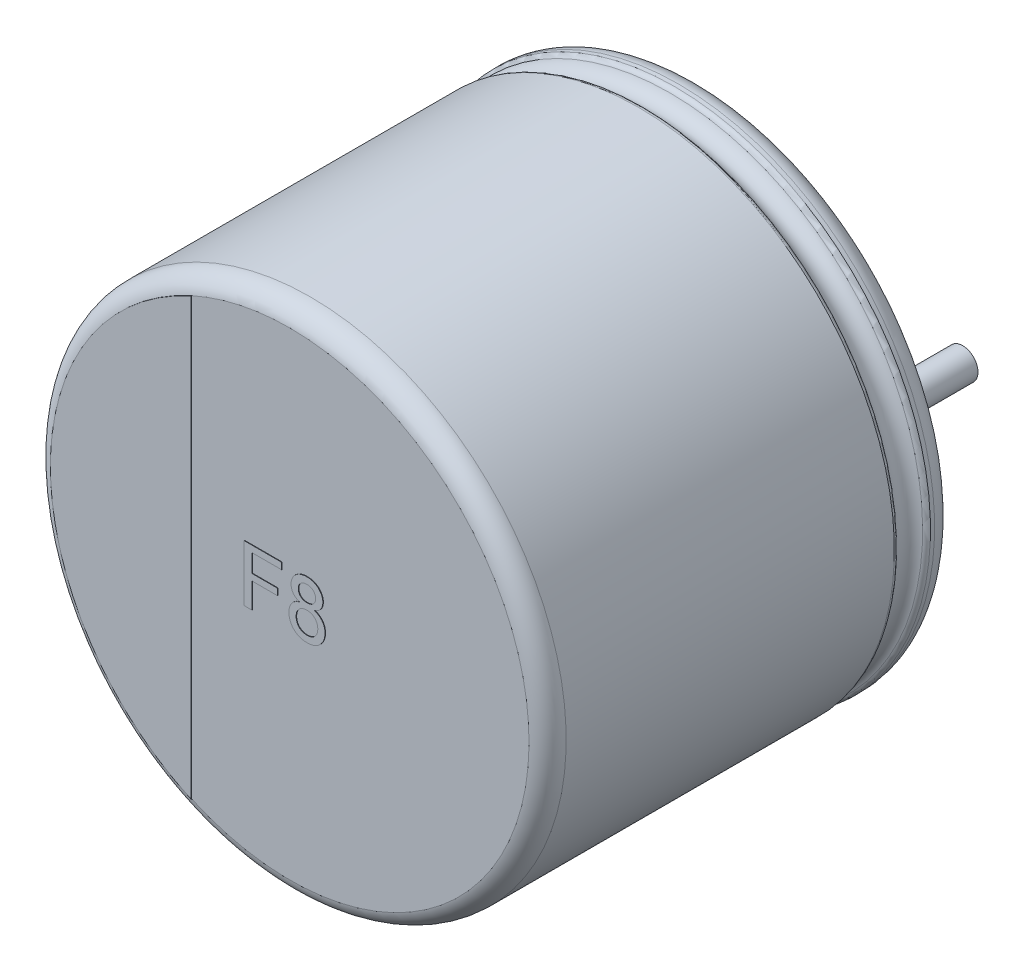
from build123d import *

# Parameters (mm, degrees)
SKETCH_2_R         = 0.3
EXTRUDE_1_DEPTH    = 2.7
EXTRUDE_2_DEPTH    = 0.01
EXTRUDE_1828_DEPTH = 0.01
EXTRUDE_5_DEPTH    = 0.05


with BuildPart() as part:
    # Sketch10 → Повернуть1 (revolve)
    with BuildSketch(Plane(origin=(0, 0, 0), x_dir=(0, 0, -1), z_dir=(1, 0, 0))):
        with BuildLine():
            Line((-8, 0), (-0.05, 0))
            Line((-0.05, 0), (-0.05, 4.403143426))
            ThreePointArc((-0.05, 4.403143426), (-0.052704561, 4.801565585), (-0.398206102, 5))
            Line((-0.398206102, 5), (-0.479422929, 5))
            ThreePointArc((-0.479422929, 5), (-0.534479696, 4.983479053), (-0.571344666, 4.939375046))
            ThreePointArc((-0.571344666, 4.939375046), (-0.831990181, 4.767472047), (-1.092635697, 4.939375046))
            ThreePointArc((-1.092635697, 4.939375046), (-1.129500666, 4.983479053), (-1.184557434, 5))
            Line((-1.184557434, 5), (-7.6, 5))
            ThreePointArc((-7.6, 5), (-7.85971595, 4.909961924), (-8, 4.67357323))
            Line((-8, 4.67357323), (-8, 0))
        make_face()
    revolve(axis=Axis((0, 0, -18.1630778), (0, 0, 1)))

    # Эскиз2 → Бобышка-Вытянуть1 (add)
    with BuildSketch(Plane(origin=(0, 0, 0.05), x_dir=(-1, 0, 0), z_dir=(0, 0, -1))):
        with Locations((-2.5, 0)):
            Circle(SKETCH_2_R)
        with Locations((2.5, 0)):
            Circle(SKETCH_2_R)
    extrude(amount=EXTRUDE_1_DEPTH)

    # Эскиз4 → Бобышка-Вытянуть2 (add)
    with BuildSketch(Plane.XY.offset(8)):
        with BuildLine():
            Line((-1.920580247, -4.260711003), (-1.920580247, 4.260711003))
            ThreePointArc((-1.920580247, 4.260711003), (-4.67357323, 0), (-1.920580247, -4.260711003))
        make_face()
    extrude(amount=EXTRUDE_2_DEPTH)

    # Эскиз5 → Extrude 1828 (add)
    with BuildSketch(Plane.XY.offset(8)):
        Polygon((-0.884369756, -0.464160183), (-0.884369756, 0.635839817), (-0.151036423, 0.635839817), (-0.151036423, 0.50891674), (-0.729241551, 0.50891674), (-0.729241551, 0.156352638), (-0.235651808, 0.156352638), (-0.235651808, 0.029429561), (-0.729241551, 0.029429561), (-0.729241551, -0.464160183), align=None)
        with BuildLine():
            add(Edge.make_bspline(
                [(0.198883449, 0.139165138), (0.185502606, 0.144399799), (0.159847092, 0.154436381), (0.125244419, 0.174522407), (0.095958787, 0.197628735), (0.072349786, 0.224312558), (0.054355434, 0.25402225), (0.04139879, 0.286379012), (0.033809856, 0.321563108), (0.032811064, 0.345892004), (0.03229691, 0.358415939)],
                knots=[0, 0, 0, 0, 4.3054e-05, 8.2549e-05, 0.000119543, 0.000154513, 0.000188827, 0.00022324, 0.000258637, 0.00029619, 0.00029619, 0.00029619, 0.00029619], degree=3))
            add(Edge.make_bspline(
                [(0.03229691, 0.358415939), (0.032538899, 0.368052555), (0.033013929, 0.386969534), (0.037118303, 0.414726997), (0.043692048, 0.441325591), (0.05302173, 0.466690245), (0.064710293, 0.491029732), (0.079459288, 0.513898142), (0.096412342, 0.535941783), (0.116272039, 0.556269584), (0.138157081, 0.574887882), (0.161861998, 0.591456339), (0.187568179, 0.605005308), (0.214847028, 0.616333389), (0.243833428, 0.625202078), (0.274629482, 0.631242149), (0.307126629, 0.635084083), (0.329394445, 0.635583982), (0.3407905, 0.635839817)],
                knots=[0, 0, 0, 0, 2.8896e-05, 5.6725e-05, 8.3981e-05, 0.000110958, 0.000137666, 0.000164808, 0.000192444, 0.000220962, 0.000249881, 0.000278549, 0.000307531, 0.000336872, 0.000367054, 0.000398298, 0.000430906, 0.000465086, 0.000465086, 0.000465086, 0.000465086], degree=3))
            add(Edge.make_bspline(
                [(0.3407905, 0.635839817), (0.352259172, 0.635581385), (0.37459885, 0.635077988), (0.407268648, 0.631287675), (0.438259045, 0.624934875), (0.467551797, 0.61592185), (0.495193084, 0.604398156), (0.521001276, 0.590234023), (0.545242053, 0.573663062), (0.567295828, 0.55448766), (0.587362135, 0.533669409), (0.604747694, 0.511366016), (0.619658735, 0.488097915), (0.63198047, 0.463723748), (0.641096136, 0.437965957), (0.64804432, 0.411309831), (0.652074588, 0.383438644), (0.652561626, 0.364525143), (0.652809731, 0.354890298)],
                knots=[0, 0, 0, 0, 3.44e-05, 6.7008e-05, 9.8512e-05, 0.00012918, 0.000158809, 0.000188196, 0.00021735, 0.000246724, 0.000275712, 0.000303967, 0.000331413, 0.000358513, 0.000385698, 0.000413222, 0.00044105, 0.000469946, 0.000469946, 0.000469946, 0.000469946], degree=3))
            add(Edge.make_bspline(
                [(0.652809731, 0.354890298), (0.652406692, 0.342798008), (0.651616409, 0.319087304), (0.64356307, 0.284908125), (0.631011253, 0.25300015), (0.612870089, 0.223971487), (0.589894979, 0.197522335), (0.561384701, 0.174529798), (0.527772233, 0.154475164), (0.502764481, 0.144405855), (0.489748833, 0.139165138)],
                knots=[0, 0, 0, 0, 3.6219e-05, 7.1019e-05, 0.000104736, 0.000138674, 0.000173188, 0.000209359, 0.000248094, 0.000290135, 0.000290135, 0.000290135, 0.000290135], degree=3))
            add(Edge.make_bspline(
                [(0.489748833, 0.139165138), (0.497960862, 0.136377543), (0.514052876, 0.130915067), (0.536802182, 0.12029433), (0.55821997, 0.108842655), (0.578427016, 0.096446209), (0.596677431, 0.082183099), (0.613580099, 0.066896643), (0.629063956, 0.050371426), (0.642917509, 0.032466898), (0.655285909, 0.013558844), (0.665874242, -0.006398833), (0.674866709, -0.027122063), (0.682551982, -0.048706942), (0.688165466, -0.071305513), (0.692093145, -0.094813923), (0.694585147, -0.119108275), (0.694938153, -0.135608468), (0.695117423, -0.143987907)],
                knots=[0, 0, 0, 0, 2.5999e-05, 5.0946e-05, 7.5198e-05, 9.8859e-05, 0.000121954, 0.000144573, 0.00016718, 0.000189791, 0.000212405, 0.000234881, 0.000257479, 0.000280128, 0.000303536, 0.000327228, 0.000351588, 0.000376723, 0.000376723, 0.000376723, 0.000376723], degree=3))
            add(Edge.make_bspline(
                [(0.695117423, -0.143987907), (0.694837165, -0.155537045), (0.694285035, -0.178289726), (0.689433844, -0.211687991), (0.682093778, -0.243771583), (0.671391114, -0.274404967), (0.657721153, -0.303609799), (0.640811246, -0.331343671), (0.620827539, -0.357578052), (0.598359515, -0.382394488), (0.573240279, -0.404827472), (0.546065918, -0.42459588), (0.516734471, -0.441154442), (0.485601829, -0.454864872), (0.452518917, -0.465490405), (0.417528262, -0.47293053), (0.380641507, -0.477360798), (0.355419487, -0.477958069), (0.342553321, -0.478262747)],
                knots=[0, 0, 0, 0, 3.463e-05, 6.8223e-05, 0.000101041, 0.000133237, 0.000165372, 0.000197607, 0.000230484, 0.000264176, 0.000297883, 0.000331338, 0.000364791, 0.000398732, 0.000433226, 0.000468839, 0.000505901, 0.000544493, 0.000544493, 0.000544493, 0.000544493], degree=3))
            add(Edge.make_bspline(
                [(0.342553321, -0.478262747), (0.329688441, -0.477951503), (0.304468944, -0.47734136), (0.267548487, -0.473001662), (0.232607895, -0.465224256), (0.199568, -0.454587923), (0.16824957, -0.441248704), (0.139115111, -0.424317035), (0.111763248, -0.404573672), (0.086626545, -0.382001935), (0.063971892, -0.357188146), (0.044251614, -0.330566323), (0.027442092, -0.302546168), (0.01360822, -0.272969725), (0.003063656, -0.241836724), (-0.004336645, -0.209264049), (-0.009196616, -0.175276591), (-0.009735569, -0.152084695), (-0.010010782, -0.140241914)],
                knots=[0, 0, 0, 0, 3.8593e-05, 7.5654e-05, 0.000111314, 0.000145808, 0.000179661, 0.000213224, 0.000246678, 0.000280697, 0.000314389, 0.00034731, 0.000379923, 0.000412257, 0.000445078, 0.000478325, 0.000512355, 0.000547865, 0.000547865, 0.000547865, 0.000547865], degree=3))
            add(Edge.make_bspline(
                [(-0.010010782, -0.140241914), (-0.009819488, -0.131424081), (-0.009444137, -0.114121969), (-0.007151245, -0.088744477), (-0.002581555, -0.064557061), (0.003304497, -0.041417182), (0.010777941, -0.019266953), (0.019997857, 0.001719682), (0.031183991, 0.021492), (0.043892172, 0.040178659), (0.058282763, 0.057648472), (0.074122527, 0.07374845), (0.091469, 0.088295469), (0.109932376, 0.101714403), (0.130286574, 0.113056035), (0.151774628, 0.123464095), (0.174765975, 0.132340241), (0.190763778, 0.136867388), (0.198883449, 0.139165138)],
                knots=[0, 0, 0, 0, 2.6457e-05, 5.1913e-05, 7.6333e-05, 0.000100222, 0.000123496, 0.000146384, 0.000168879, 0.000191554, 0.000214096, 0.00023669, 0.000259205, 0.000281951, 0.000305046, 0.000328996, 0.000353549, 0.000378855, 0.000378855, 0.000378855, 0.000378855], degree=3))
        make_face()
        with BuildLine():
            add(Edge.make_bspline(
                [(0.173322551, 0.357754881), (0.173741114, 0.346528252), (0.174549962, 0.324833422), (0.183346276, 0.294017507), (0.197101157, 0.266336173), (0.213226342, 0.246262311), (0.228686344, 0.23258495), (0.241589845, 0.223453062), (0.255690876, 0.215700274), (0.271091593, 0.209674318), (0.28741899, 0.204335696), (0.305236175, 0.201351795), (0.324124366, 0.19892606), (0.337182213, 0.19875038), (0.343875436, 0.19866033)],
                knots=[0, 0, 0, 0, 3.3598e-05, 6.4926e-05, 9.5278e-05, 0.000125837, 0.000141446, 0.000157097, 0.000173171, 0.00018958, 0.000206655, 0.000224591, 0.000243669, 0.000263732, 0.000263732, 0.000263732, 0.000263732], degree=3))
            add(Edge.make_bspline(
                [(0.343875436, 0.19866033), (0.350420912, 0.198753708), (0.363184232, 0.19893579), (0.381647016, 0.201312071), (0.399094283, 0.204485818), (0.415268213, 0.209295143), (0.430355533, 0.215548669), (0.444110855, 0.223257723), (0.456945804, 0.232117638), (0.471951648, 0.245899493), (0.48805458, 0.265270289), (0.501855558, 0.291715059), (0.510455739, 0.320647206), (0.511333533, 0.340800134), (0.51178409, 0.351144304)],
                knots=[0, 0, 0, 0, 1.9623e-05, 3.8263e-05, 5.5765e-05, 7.2777e-05, 8.8778e-05, 0.000104658, 0.000120003, 0.000135448, 0.000165665, 0.000195037, 0.000224397, 0.00025536, 0.00025536, 0.00025536, 0.00025536], degree=3))
            add(Edge.make_bspline(
                [(0.51178409, 0.351144304), (0.511241232, 0.361850078), (0.510178999, 0.382798504), (0.501599825, 0.412870914), (0.487156034, 0.440107537), (0.470656006, 0.459998057), (0.455384708, 0.474407567), (0.442319335, 0.483580186), (0.428274009, 0.491386895), (0.413195276, 0.497762125), (0.397061329, 0.502903814), (0.379828465, 0.506277009), (0.361569095, 0.50864275), (0.349025285, 0.508823488), (0.342553321, 0.50891674)],
                knots=[0, 0, 0, 0, 3.2079e-05, 6.2771e-05, 9.2933e-05, 0.000123941, 0.000139846, 0.000155805, 0.000171686, 0.000187975, 0.000204841, 0.000222386, 0.000240589, 0.000259991, 0.000259991, 0.000259991, 0.000259991], degree=3))
            add(Edge.make_bspline(
                [(0.342553321, 0.50891674), (0.336080636, 0.508826504), (0.323462453, 0.508650594), (0.30508402, 0.506213862), (0.28768784, 0.503153376), (0.271434404, 0.498241863), (0.256391273, 0.491823657), (0.242401322, 0.484012562), (0.229360704, 0.475074244), (0.213982115, 0.461307276), (0.197875577, 0.441936041), (0.18368617, 0.415913626), (0.174916657, 0.387540412), (0.173860501, 0.367806367), (0.173322551, 0.357754881)],
                knots=[0, 0, 0, 0, 1.9402e-05, 3.7824e-05, 5.5543e-05, 7.2343e-05, 8.8633e-05, 0.000104513, 0.000120345, 0.000135954, 0.000166312, 0.000195399, 0.000224399, 0.000254503, 0.000254503, 0.000254503, 0.000254503], degree=3))
        make_face(mode=Mode.SUBTRACT)
        with BuildLine():
            add(Edge.make_bspline(
                [(0.131014859, -0.137597683), (0.131258724, -0.14664666), (0.131747097, -0.164768452), (0.136031177, -0.191683153), (0.143300372, -0.218096652), (0.152617112, -0.2440339), (0.165758953, -0.268448024), (0.183186511, -0.290239426), (0.205054833, -0.308560323), (0.230029653, -0.324038512), (0.257283602, -0.336221178), (0.285683015, -0.344725093), (0.314494915, -0.350344055), (0.333933916, -0.35100776), (0.343655083, -0.35133967)],
                knots=[0, 0, 0, 0, 2.7136e-05, 5.4343e-05, 8.1496e-05, 0.000109247, 0.000136857, 0.000164284, 0.000192415, 0.000222009, 0.000252191, 0.000281676, 0.000310806, 0.000339946, 0.000339946, 0.000339946, 0.000339946], degree=3))
            add(Edge.make_bspline(
                [(0.343655083, -0.35133967), (0.351671235, -0.351203882), (0.367244331, -0.350940085), (0.389945031, -0.34792564), (0.411334221, -0.343351741), (0.431509897, -0.337080176), (0.450175095, -0.328500259), (0.46763377, -0.3184722), (0.483707342, -0.306352522), (0.498391261, -0.292520912), (0.511535971, -0.277220558), (0.522796078, -0.260714819), (0.532618402, -0.243467879), (0.54063788, -0.225107523), (0.546437255, -0.205595888), (0.550912293, -0.185285008), (0.55361195, -0.163965388), (0.55392952, -0.149431045), (0.554091782, -0.142004734)],
                knots=[0, 0, 0, 0, 2.4035e-05, 4.6692e-05, 6.8562e-05, 8.9607e-05, 0.000109923, 0.000130067, 0.000149899, 0.000170164, 0.000190479, 0.000210283, 0.000230016, 0.000249952, 0.000270235, 0.000290981, 0.0003123, 0.000334573, 0.000334573, 0.000334573, 0.000334573], degree=3))
            add(Edge.make_bspline(
                [(0.554091782, -0.142004734), (0.553924352, -0.134432654), (0.553596552, -0.119607726), (0.550965501, -0.097820183), (0.546239533, -0.077151964), (0.540161917, -0.057290831), (0.531925011, -0.038582311), (0.522037757, -0.020758146), (0.509929889, -0.004288141), (0.496652646, 0.011386862), (0.481627252, 0.025576363), (0.465034515, 0.037812505), (0.447400296, 0.048619092), (0.428191143, 0.056908656), (0.40783026, 0.063548786), (0.386220916, 0.068373605), (0.363275004, 0.071322888), (0.347557156, 0.071596464), (0.339468385, 0.071737253)],
                knots=[0, 0, 0, 0, 2.2713e-05, 4.4469e-05, 6.5693e-05, 8.6252e-05, 0.00010668, 0.000126905, 0.00014727, 0.000167896, 0.000188473, 0.000209098, 0.000229656, 0.000250373, 0.000271696, 0.000293828, 0.000316705, 0.00034096, 0.00034096, 0.00034096, 0.00034096], degree=3))
            add(Edge.make_bspline(
                [(0.339468385, 0.071737253), (0.33159927, 0.071595063), (0.316173354, 0.071316327), (0.293763762, 0.068350337), (0.272548763, 0.063795561), (0.252715009, 0.057129038), (0.234014514, 0.048798541), (0.216789306, 0.038323537), (0.200732088, 0.026165046), (0.18633335, 0.012033113), (0.173341957, -0.003318008), (0.162109506, -0.019774363), (0.152186774, -0.036954213), (0.144656623, -0.055421292), (0.138283024, -0.074578593), (0.134298516, -0.094797939), (0.131466029, -0.115849602), (0.131167447, -0.130242366), (0.131014859, -0.137597683)],
                knots=[0, 0, 0, 0, 2.3594e-05, 4.6252e-05, 6.7691e-05, 8.8595e-05, 0.000108911, 0.000128977, 0.000148942, 0.0001692, 0.000189373, 0.000209177, 0.00022891, 0.000248759, 0.000268898, 0.000289383, 0.000310482, 0.000332535, 0.000332535, 0.000332535, 0.000332535], degree=3))
        make_face(mode=Mode.SUBTRACT)
    extrude(amount=EXTRUDE_1828_DEPTH)

    # Эскиз6 → Бобышка-Вытянуть5 (add)
    with BuildSketch(Plane(origin=(0, 0, 0.05), x_dir=(-1, 0, 0), z_dir=(0, 0, -1))):
        with BuildLine():
            Line((-2.5, 0.624675577), (-2.607190564, 0.624675577))
            ThreePointArc((-2.607190564, 0.624675577), (-2.810142517, 0.728694397), (-2.844207888, 0.954191538))
            ThreePointArc((-2.844207888, 0.954191538), (0, 3), (2.844207888, 0.954191538))
            ThreePointArc((2.844207888, 0.954191538), (2.810142517, 0.728694397), (2.607190564, 0.624675577))
            Line((2.607190564, 0.624675577), (2.5, 0.624675577))
            ThreePointArc((2.5, 0.624675577), (1.875324423, 0), (2.5, -0.624675577))
            Line((2.5, -0.624675577), (2.607190564, -0.624675577))
            ThreePointArc((2.607190564, -0.624675577), (2.810142517, -0.728694397), (2.844207888, -0.954191538))
            ThreePointArc((2.844207888, -0.954191538), (0, -3), (-2.844207888, -0.954191538))
            ThreePointArc((-2.844207888, -0.954191538), (-2.810142517, -0.728694397), (-2.607190564, -0.624675577))
            Line((-2.607190564, -0.624675577), (-2.5, -0.624675577))
            ThreePointArc((-2.5, -0.624675577), (-1.875324423, 0), (-2.5, 0.624675577))
        make_face()
    extrude(amount=EXTRUDE_5_DEPTH)


solid = part.part
